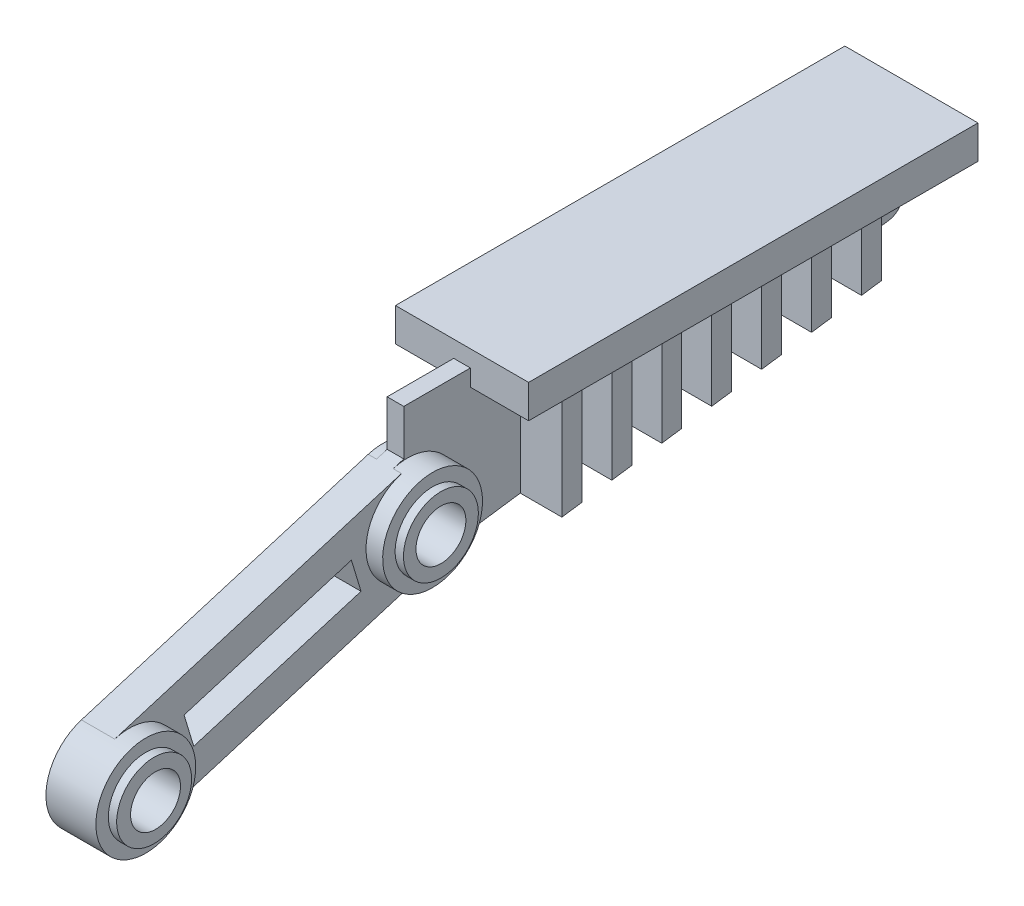
from build123d import *

# Parameters (mm, degrees)
SKETCH1_W           = 8
SKETCH1_H           = 27
BOSS_EXTRUDE1_DEPTH = 2
BOSS_EXTRUDE2_DEPTH = 0.5
BOSS_EXTRUDE3_DEPTH = 0.5
BOSS_EXTRUDE4_DEPTH = 0.5
SKETCH7_R           = 2.25
BOSS_EXTRUDE5_DEPTH = 0.5
SKETCH8_R           = 3
BOSS_EXTRUDE6_DEPTH = 1
SKETCH9_R           = 2.25
BOSS_EXTRUDE7_DEPTH = 0.5
SKETCH14_W          = 10.5
SKETCH14_H          = 2
CUT_EXTRUDE2_DEPTH  = 1.8
FILLET1_R           = 1
SKETCH15_W          = 4
SKETCH15_H          = 3.5
CUT_EXTRUDE5_DEPTH  = 0.1
SKETCH19_W          = 6
SKETCH19_H          = 1.2
BOSS_EXTRUDE8_DEPTH = 7.1
LPATTERN1_COUNT     = 7
LPATTERN1_PITCH     = 3
SKETCH20_W          = 19.979424
SKETCH20_H          = 3.421259
CUT_EXTRUDE6_DEPTH  = 3.55
SKETCH10_R          = 1.5
CUT_EXTRUDE7_DEPTH  = 7.5
BOSS_EXTRUDE9_DEPTH = 0.5


with BuildPart() as part:
    # Sketch1 → Boss-Extrude1 (new body)
    with BuildSketch(Plane(origin=(0, 0, 0), x_dir=(1, 0, 0), z_dir=(0, 1, 0))):
        Rectangle(SKETCH1_W, SKETCH1_H)
    extrude(amount=-BOSS_EXTRUDE1_DEPTH)

    # Sketch4 → Boss-Extrude2 (add, symmetric)
    with BuildSketch(Plane(origin=(0, 0, 0), x_dir=(0, 0, -1), z_dir=(1, 0, 0))):
        with BuildLine():
            Line((13.5, 0), (13.5, -2))
            Line((13.5, -2), (12.263932, -5.804226))
            Line((12.263932, -5.804226), (-17.5, -10))
            Line((-17.5, -10), (-33.632717, -14.871902))
            ThreePointArc((-33.632717, -14.871902), (-37.371902, -12.867283), (-35.367283, -9.128098))
            Line((-35.367283, -9.128098), (-19.234565, -4.256196))
            Line((-19.234565, -4.256196), (-17.501224, -3.732746))
            Line((-17.501224, -3.732746), (-17.5, -1))
            Line((-17.5, -1), (-13.5, -1))
            Line((-13.5, -1), (-13.5, 0))
            Line((-13.5, 0), (13.5, 0))
        make_face()
    extrude(amount=BOSS_EXTRUDE2_DEPTH, both=True)

    # Sketch5 → Boss-Extrude3 (add)
    with BuildSketch(Plane.ZY.offset(0.5)):
        with BuildLine():
            Line((33.632717, -14.871902), (16.422266, -9.674453))
            ThreePointArc((16.422266, -9.674453), (14.393544, -5.939496), (18.135871, -3.924403))
            Line((18.135871, -3.924403), (35.367283, -9.128098))
            ThreePointArc((35.367283, -9.128098), (37.371898, -12.867295), (33.632717, -14.871902))
        make_face()
    extrude(amount=BOSS_EXTRUDE3_DEPTH)

    # Sketch6 → Boss-Extrude4 (add)
    with BuildSketch(Plane(origin=(0.5, 0, 0), x_dir=(0, 0, -1), z_dir=(1, 0, 0))):
        with BuildLine():
            Line((-35.367283, -9.128098), (-18.135871, -3.924403))
            ThreePointArc((-18.135871, -3.924403), (-14.396686, -5.929022), (-16.401306, -9.668206))
            Line((-16.401306, -9.668206), (-33.632717, -14.871902))
            ThreePointArc((-33.632717, -14.871902), (-37.371902, -12.867283), (-35.367283, -9.128098))
        make_face()
    extrude(amount=BOSS_EXTRUDE4_DEPTH)

    # Sketch7 → Boss-Extrude5 (add)
    with BuildSketch(Plane.ZY.offset(1)):
        with Locations((17.268588, -6.796304)):
            Circle(SKETCH7_R)
    extrude(amount=BOSS_EXTRUDE5_DEPTH)

    # Sketch8 → Boss-Extrude6 (add)
    with BuildSketch(Plane(origin=(1, 0, 0), x_dir=(0, 0, -1), z_dir=(1, 0, 0))):
        with Locations((-34.5, -12)):
            Circle(SKETCH8_R)
        with Locations((-17.268588, -6.796304)):
            Circle(SKETCH8_R)
    extrude(amount=BOSS_EXTRUDE6_DEPTH)

    # Sketch9 → Boss-Extrude7 (add)
    with BuildSketch(Plane(origin=(2, 0, 0), x_dir=(0, 0, -1), z_dir=(1, 0, 0))):
        with Locations((-34.5, -12)):
            Circle(SKETCH9_R)
        with Locations((-17.268588, -6.796304)):
            Circle(SKETCH9_R)
    extrude(amount=BOSS_EXTRUDE7_DEPTH)

    # Sketch14 → Cut-Extrude2 (cut)
    with BuildSketch(Plane(origin=(1, 0, 0), x_dir=(0, 0.289094, -0.957301), z_dir=(-1, 0, 0))):
        with Locations((-27.496003, 1.513858)):
            Rectangle(SKETCH14_W, SKETCH14_H)
    extrude(amount=CUT_EXTRUDE2_DEPTH, mode=Mode.SUBTRACT)

    # Fillet1
    fillet1_edges = [part.edges().sort_by_distance(p)[0] for p in [
        (0, -5.804226, -12.263932),
    ]]
    fillet(fillet1_edges, radius=FILLET1_R)

    # Sketch15 → Cut-Extrude5 (cut)
    with BuildSketch(Plane(origin=(-1, 0, 0), x_dir=(0, 0.289098, -0.957299), z_dir=(1, 0, 0))):
        with Locations((-27.49601, -1.513736)):
            Rectangle(SKETCH15_W, SKETCH15_H)
    extrude(amount=CUT_EXTRUDE5_DEPTH, mode=Mode.SUBTRACT)

    # Sketch19 → Boss-Extrude8 (add)
    with BuildSketch(Plane.XZ.offset(2)):
        with Locations((0, 9.9)):
            Rectangle(SKETCH19_W, SKETCH19_H)
    boss_extrude8 = extrude(amount=BOSS_EXTRUDE8_DEPTH)

    # LPattern1: Boss-Extrude8 ×7
    with Locations(*[(0, 0, -i * LPATTERN1_PITCH) for i in range(1, LPATTERN1_COUNT)]):
        add(boss_extrude8)

    # Sketch20 → Cut-Extrude6 (cut, symmetric)
    with BuildSketch(Plane(origin=(0.5, 0, 0), x_dir=(0, 0.139588, -0.99021), z_dir=(-1, 0, 0))):
        with Locations((-2.255219, 9.169932)):
            Rectangle(SKETCH20_W, SKETCH20_H)
    extrude(amount=CUT_EXTRUDE6_DEPTH, both=True, mode=Mode.SUBTRACT)

    # Sketch10 → Cut-Extrude7 (cut, through all)
    with BuildSketch(Plane(origin=(2.5, 0, 0), x_dir=(0, 0, -1), z_dir=(1, 0, 0))):
        with Locations((-17.268588, -6.796304)):
            Circle(SKETCH10_R)
        with Locations((-34.415724, -12.051332)):
            Circle(SKETCH10_R)
    extrude(amount=-CUT_EXTRUDE7_DEPTH, mode=Mode.SUBTRACT)

    # Sketch21 → Boss-Extrude9 (add)
    with BuildSketch(Plane(origin=(-0.8, 0, 0), x_dir=(0, 0, -1), z_dir=(1, 0, 0))):
        Polygon((-27.695614, -9.145204), (-29.158321, -10.509201), (-28.817322, -10.874878), (-27.354614, -9.510881), align=None)
    extrude(amount=BOSS_EXTRUDE9_DEPTH)


solid = part.part
